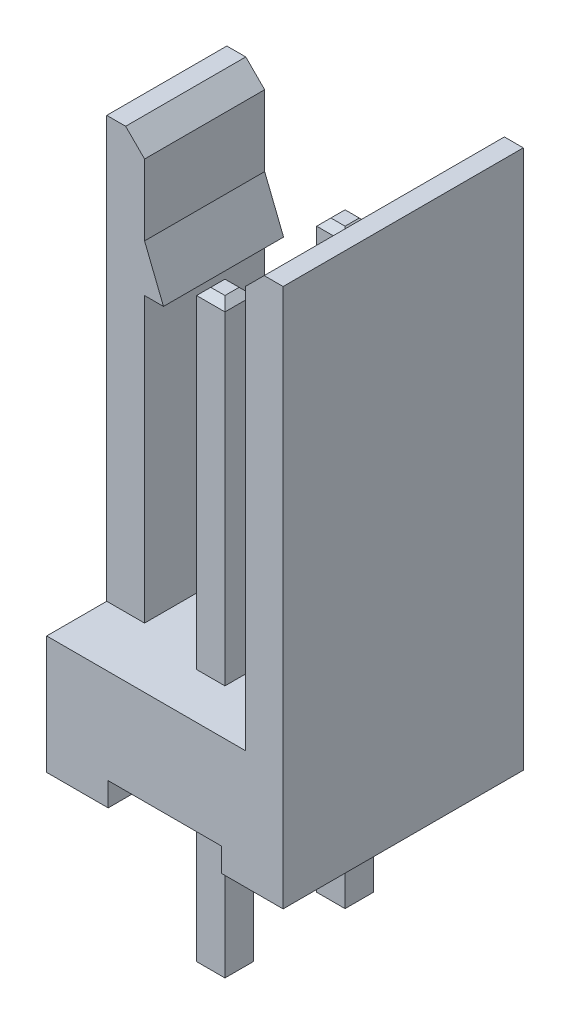
from build123d import *

# Parameters (mm, degrees)
BOSS_EXTRU_1_DEPTH      = 5.08
ESQUISSE3_W             = 0.8
ESQUISSE3_H             = 1.27
ENL_V_MAT_EXTRU_1_DEPTH = 8.9
ESQUISSE4_W             = 2.4
ESQUISSE4_H             = 0.5
ENL_V_MAT_EXTRU_2_DEPTH = 6.08
ESQUISSE2_W             = 0.6
ESQUISSE2_H             = 0.6
BOSS_EXTRU_2_DEPTH      = 3.5
BOSS_EXTRU_2_DEPTH_BACK = 9
BOSS_EXTRU_3_DEPTH      = 2.54
CHANFREIN4_SIZE         = 0.15
CHANFREIN5_SIZE         = 0.4


with BuildPart() as part:
    # Esquisse1 → Boss.-Extru.1 (new body)
    with BuildSketch(Plane.XY):
        Polygon((0, 11.4), (0, 0), (5, 0), (5, 11.4), (4.2, 11.4), (4.2, 2.5), (0.8, 2.5), (0.8, 11.4), align=None)
    extrude(amount=BOSS_EXTRU_1_DEPTH)

    # Esquisse3 → Enlèv. mat.-Extru.1 (cut)
    with BuildSketch(Plane(origin=(0, 11.4, 0), x_dir=(1, 0, 0), z_dir=(0, 1, 0))):
        with Locations((0.4, -0.635)):
            Rectangle(ESQUISSE3_W, ESQUISSE3_H)
        with Locations((0.4, -4.445)):
            Rectangle(ESQUISSE3_W, ESQUISSE3_H)
    extrude(amount=-ENL_V_MAT_EXTRU_1_DEPTH, mode=Mode.SUBTRACT)

    # Esquisse4 → Enlèv. mat.-Extru.2 (cut, through all)
    with BuildSketch(Plane.XY.offset(5.08)):
        with Locations((2.5, 0.25)):
            Rectangle(ESQUISSE4_W, ESQUISSE4_H)
    extrude(amount=-ENL_V_MAT_EXTRU_2_DEPTH, mode=Mode.SUBTRACT)

    # Esquisse2 → Boss.-Extru.2 (add, two sides)
    with BuildSketch(Plane.XZ.offset(-0.5)) as boss_extru_2_sk:
        with Locations((2.5, 3.81)):
            Rectangle(ESQUISSE2_W, ESQUISSE2_H)
        with Locations((2.5, 1.27)):
            Rectangle(ESQUISSE2_W, ESQUISSE2_H)
    extrude(amount=BOSS_EXTRU_2_DEPTH)
    extrude(boss_extru_2_sk.sketch, amount=-BOSS_EXTRU_2_DEPTH_BACK)

    # Esquisse5 → Boss.-Extru.3 (add)
    with BuildSketch(Plane.XY.offset(3.81)):
        Polygon((0.8, 9.5), (1.2, 8.5), (0.8, 8.5), align=None)
    extrude(amount=-BOSS_EXTRU_3_DEPTH)

    # Chanfrein4
    chanfrein4_edges = [part.edges().sort_by_distance(p)[0] for p in [
        (2.8, 9.5, 3.81),
        (2.5, 9.5, 3.51),
        (2.2, 9.5, 3.81),
        (2.5, 9.5, 4.11),
        (2.8, -3, 3.81),
        (2.5, -3, 4.11),
        (2.2, -3, 3.81),
        (2.5, -3, 3.51),
        (2.8, 9.5, 1.27),
        (2.5, 9.5, 0.97),
        (2.2, 9.5, 1.27),
        (2.5, 9.5, 1.57),
        (2.8, -3, 1.27),
        (2.5, -3, 1.57),
        (2.2, -3, 1.27),
        (2.5, -3, 0.97),
    ]]
    chamfer(chanfrein4_edges, length=CHANFREIN4_SIZE)

    # Chanfrein5
    chanfrein5_edges = [part.edges().sort_by_distance(p)[0] for p in [
        (4.2, 11.4, 2.54),
        (0.8, 11.4, 2.54),
    ]]
    chamfer(chanfrein5_edges, length=CHANFREIN5_SIZE)


solid = part.part
